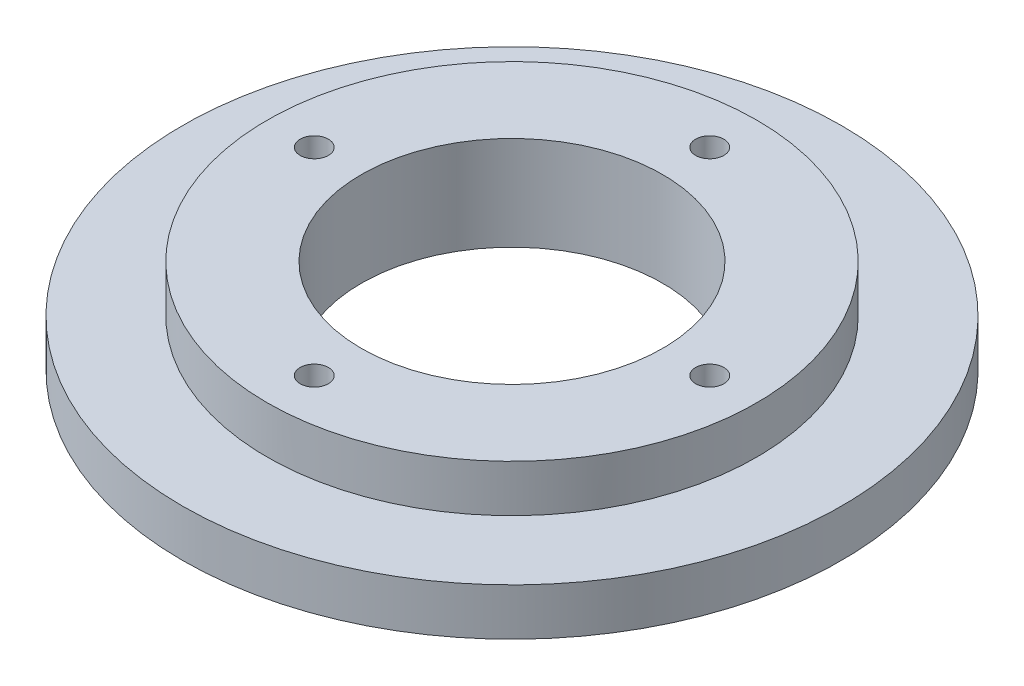
from build123d import *

# Parameters (mm, degrees)
ESQUISSE1_R             = 26
ESQUISSE1_R_2           = 16
BOSS_EXTRU_1_DEPTH      = 10
ESQUISSE2_R             = 35
BOSS_EXTRU_2_DEPTH      = 5
ESQUISSE3_R             = 16
ENL_V_MAT_EXTRU_1_DEPTH = 5
ESQUISSE4_R             = 1.5
ENL_V_MAT_EXTRU_2_DEPTH = 35
ENL_V_MAT_EXTRU_3_DEPTH = 3


with BuildPart() as part:
    # Esquisse1 → Boss.-Extru.1 (new body)
    with BuildSketch(Plane(origin=(0, 0, 0), x_dir=(1, 0, 0), z_dir=(0, 1, 0))):
        Circle(ESQUISSE1_R)
        Circle(ESQUISSE1_R_2, mode=Mode.SUBTRACT)
    extrude(amount=BOSS_EXTRU_1_DEPTH)

    # Esquisse2 → Boss.-Extru.2 (add)
    with BuildSketch(Plane.XZ):
        Circle(ESQUISSE2_R)
    extrude(amount=-BOSS_EXTRU_2_DEPTH)

    # Esquisse3 → Enlèv. mat.-Extru.1 (cut)
    with BuildSketch(Plane(origin=(0, 5, 0), x_dir=(1, 0, 0), z_dir=(0, 1, 0))):
        Circle(ESQUISSE3_R)
    extrude(amount=-ENL_V_MAT_EXTRU_1_DEPTH, mode=Mode.SUBTRACT)

    # Esquisse4 → Enlèv. mat.-Extru.2 (cut)
    with BuildSketch(Plane(origin=(0, 10, 0), x_dir=(1, 0, 0), z_dir=(0, 1, 0))):
        with Locations((-21, 0)):
            Circle(ESQUISSE4_R)
        with Locations((21, 0)):
            Circle(ESQUISSE4_R)
        with Locations((0, -21)):
            Circle(ESQUISSE4_R)
        with Locations((0, 21)):
            Circle(ESQUISSE4_R)
    extrude(amount=-ENL_V_MAT_EXTRU_2_DEPTH, mode=Mode.SUBTRACT)

    # Esquisse5 → Enlèv. mat.-Extru.3 (cut)
    with BuildSketch(Plane.XZ):
        Polygon((24.031088913, 0), (22.515544457, 2.625), (19.484455543, 2.625), (17.968911087, 0), (19.484455543, -2.625), (22.515544457, -2.625), align=None)
        Polygon((3.031088913, -21), (1.515544457, -18.375), (-1.515544457, -18.375), (-3.031088913, -21), (-1.515544457, -23.625), (1.515544457, -23.625), align=None)
        Polygon((-17.968911087, 0), (-19.484455543, 2.625), (-22.515544457, 2.625), (-24.031088913, 0), (-22.515544457, -2.625), (-19.484455543, -2.625), align=None)
        Polygon((3.031088913, 21), (1.515544457, 23.625), (-1.515544457, 23.625), (-3.031088913, 21), (-1.515544457, 18.375), (1.515544457, 18.375), align=None)
    extrude(amount=-ENL_V_MAT_EXTRU_3_DEPTH, mode=Mode.SUBTRACT)


solid = part.part
